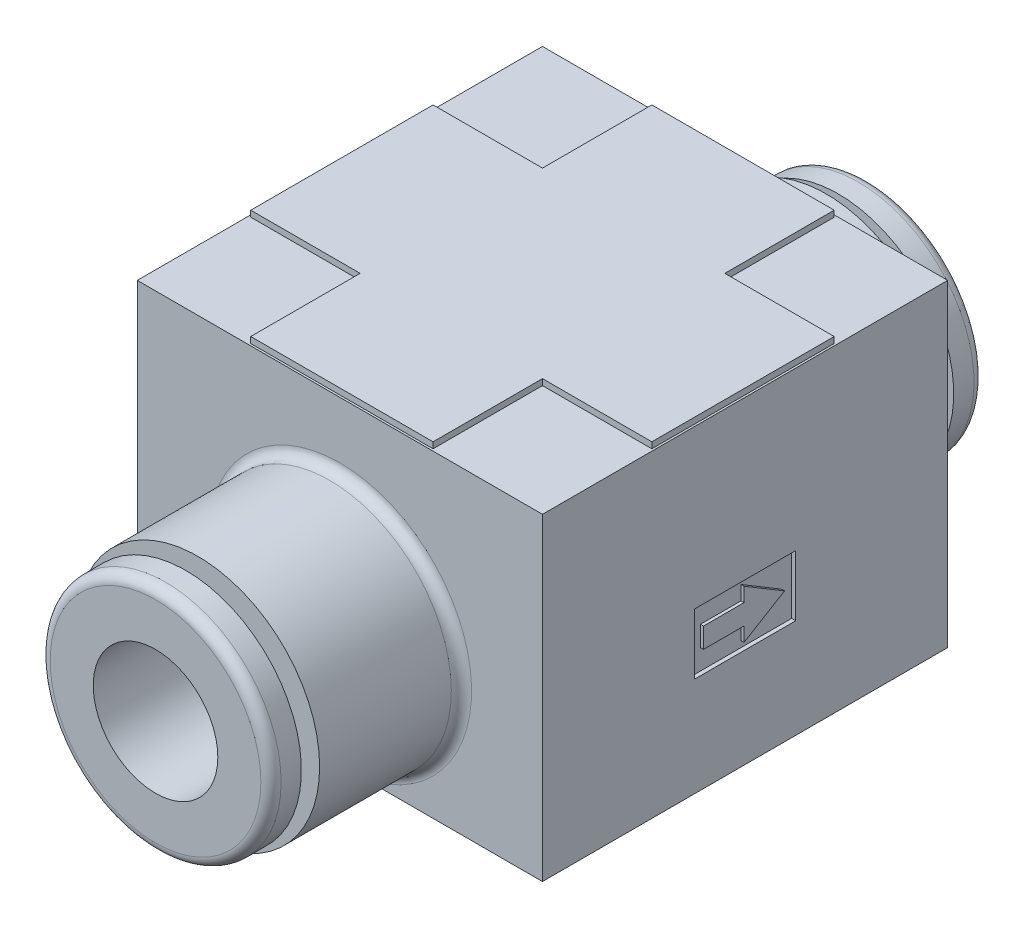
from build123d import *

# Parameters (mm, degrees)
SKETCH1_W                      = 20
SKETCH1_H                      = 15.7
BOSS_EXTRUDE1_DEPTH            = 10
SKETCH3_R                      = 6
BOSS_EXTRUDE2_DEPTH            = 17
BOSS_EXTRUDE2_DEPTH_BACK       = 14
FILLET1_R                      = 0.5
SKETCH4_W                      = 5
SKETCH4_H                      = 3
CUT_EXTRUDE1_DEPTH             = 0.2
BOSS_EXTRUDE3_DEPTH            = 0.15
FILLET2_R                      = 0.5
ONE_TOUCH_PORT_D               = 6.15
ONE_TOUCH_PORT_DEPTH           = 6
ONE_TOUCH_PORT_ON_FACE_2_D     = 6.15
ONE_TOUCH_PORT_ON_FACE_2_DEPTH = 6
BOSS_EXTRUDE4_DEPTH            = 0.3


with BuildPart() as part:
    # Sketch1 → Boss-Extrude1 (new body, symmetric)
    with BuildSketch(Plane.XY):
        with Locations((0, 1.45)):
            Rectangle(SKETCH1_W, SKETCH1_H)
    extrude(amount=BOSS_EXTRUDE1_DEPTH, both=True)

    # Sketch3 → Boss-Extrude2 (add, two sides)
    with BuildSketch(Plane.XY) as boss_extrude2_sk:
        Circle(SKETCH3_R)
    extrude(amount=BOSS_EXTRUDE2_DEPTH)
    extrude(boss_extrude2_sk.sketch, amount=-BOSS_EXTRUDE2_DEPTH_BACK)

    # Fillet1
    fillet1_edges = [part.edges().sort_by_distance(p)[0] for p in [
        (-6, 0, 10),
        (-6, 0, -10),
    ]]
    fillet(fillet1_edges, radius=FILLET1_R)

    # Sketch4 → Cut-Extrude1 (cut)
    with BuildSketch(Plane(origin=(10, 0, 0), x_dir=(0, 0, -1), z_dir=(1, 0, 0))):
        Rectangle(SKETCH4_W, SKETCH4_H)
    extrude(amount=-CUT_EXTRUDE1_DEPTH, mode=Mode.SUBTRACT)

    # Sketch5 → Boss-Extrude3 (add)
    with BuildSketch(Plane(origin=(9.8, 0, 0), x_dir=(0, 0, -1), z_dir=(1, 0, 0))):
        Polygon((0, 1.2), (2, 0), (0, -1.2), (0, -0.5), (-2, -0.5), (-2, 0.5), (0, 0.5), align=None)
    extrude(amount=BOSS_EXTRUDE3_DEPTH)

    # Sketch8 → Revolve2 (revolve)
    with BuildSketch(Plane(origin=(0, 0, 0), x_dir=(0, 0, -1), z_dir=(1, 0, 0))):
        Polygon((-17, 0), (-19.1, 0), (-19.1, 5.7), (-17.6, 5.7), (-17.6, 3.15), (-17, 3.15), align=None)
    revolve2 = revolve(axis=Axis((0, 0, -80.9), (0, 0, 1)))

    # Mirror1: Revolve2 across plane
    add(revolve2.mirror(Plane.XY.offset(1.5)))

    # Fillet2
    fillet2_edges = [part.edges().sort_by_distance(p)[0] for p in [
        (0, -5.7, 19.1),
        (0, -3.15, 17.6),
        (0, -5.7, -16.1),
        (0, -3.15, -14.6),
    ]]
    fillet(fillet2_edges, radius=FILLET2_R)

    # One Touch Port
    with Locations(Plane.XY.offset(19.1)):
        with Locations((0, 0)):
            Hole(ONE_TOUCH_PORT_D / 2, depth=ONE_TOUCH_PORT_DEPTH)

    # One Touch Port on face 2
    with Locations(Plane(origin=(0, 0, -16.1), x_dir=(-1, 0, 0), z_dir=(0, 0, -1))):
        with Locations((0, 0)):
            Hole(ONE_TOUCH_PORT_ON_FACE_2_D / 2, depth=ONE_TOUCH_PORT_ON_FACE_2_DEPTH)

    # Sketch11 → Boss-Extrude4 (add)
    with BuildSketch(Plane(origin=(0, 9.3, 0), x_dir=(1, 0, 0), z_dir=(0, 1, 0))):
        Polygon((-9.9, -4.5), (-4.5, -4.5), (-4.5, -9.9), (4.5, -9.9), (4.5, -4.5), (9.9, -4.5), (9.9, 4.5), (4.5, 4.5), (4.5, 9.9), (-4.5, 9.9), (-4.5, 4.5), (-9.9, 4.5), align=None)
    extrude(amount=BOSS_EXTRUDE4_DEPTH)


solid = part.part
